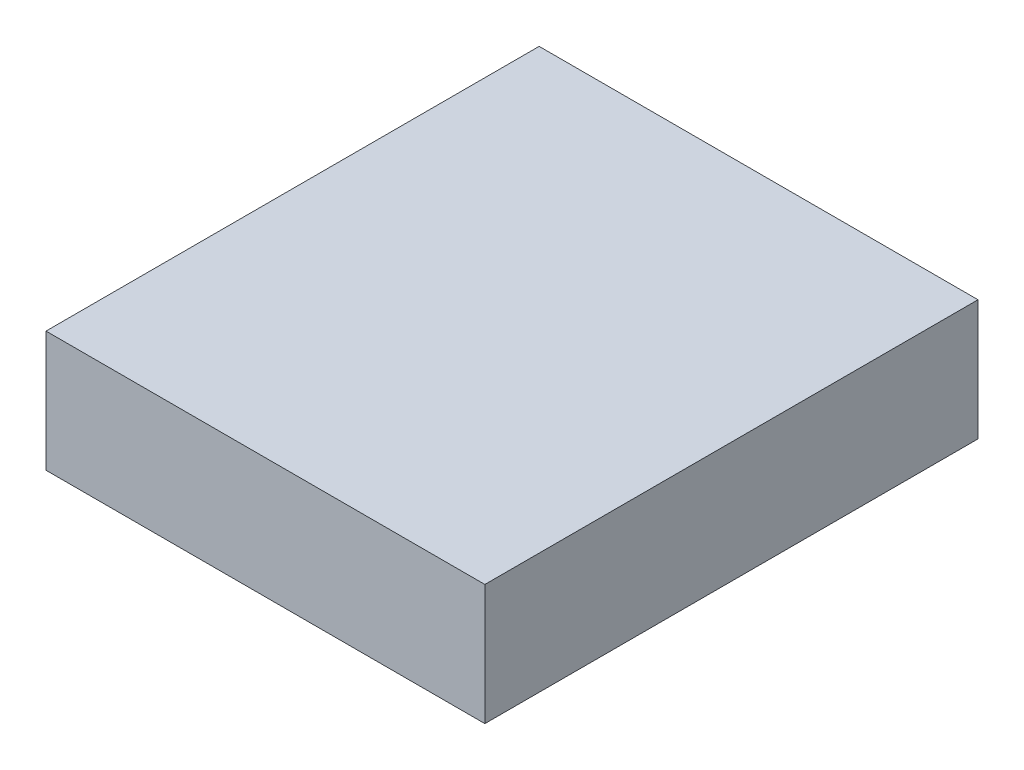
from build123d import *

# Parameters (mm, degrees)
SKETCH1_W           = 84.1
SKETCH1_H           = 94.5
BOSS_EXTRUDE1_DEPTH = 11.55


with BuildPart() as part:
    # Sketch1 → Boss-Extrude1 (new body, symmetric)
    with BuildSketch(Plane(origin=(0, 0, 0), x_dir=(1, 0, 0), z_dir=(0, 1, 0))):
        Rectangle(SKETCH1_W, SKETCH1_H)
    extrude(amount=BOSS_EXTRUDE1_DEPTH, both=True)


solid = part.part
